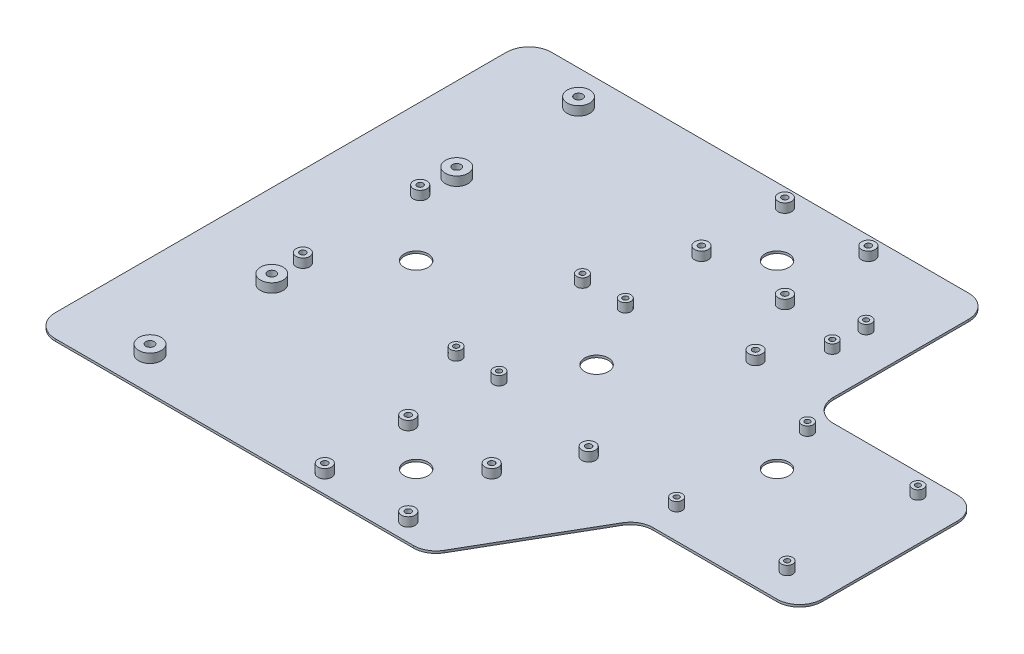
from build123d import *

# Parameters (mm, degrees)
SKETCH1_R              = 5
SKETCH1_R_2            = 1.85
BOSS_EXTRUDE1_DEPTH    = 5
SKETCH1_R_3            = 3
SKETCH1_R_4            = 1.35
BOSS_EXTRUDE1_2_DEPTH  = 5
BOSS_EXTRUDE1_3_DEPTH  = 5
BOSS_EXTRUDE1_4_DEPTH  = 5
BOSS_EXTRUDE1_5_DEPTH  = 5
SKETCH1_R_5            = 2.5
SKETCH1_R_6            = 1.15
BOSS_EXTRUDE1_6_DEPTH  = 5
BOSS_EXTRUDE1_7_DEPTH  = 5
BOSS_EXTRUDE1_8_DEPTH  = 5
BOSS_EXTRUDE1_9_DEPTH  = 5
BOSS_EXTRUDE1_10_DEPTH = 5
BOSS_EXTRUDE1_11_DEPTH = 5
BOSS_EXTRUDE1_12_DEPTH = 5
BOSS_EXTRUDE1_13_DEPTH = 5
BOSS_EXTRUDE1_14_DEPTH = 5
BOSS_EXTRUDE1_15_DEPTH = 5
BOSS_EXTRUDE1_16_DEPTH = 5
BOSS_EXTRUDE1_17_DEPTH = 5
BOSS_EXTRUDE1_18_DEPTH = 5
BOSS_EXTRUDE1_19_DEPTH = 5
BOSS_EXTRUDE1_20_DEPTH = 5
BOSS_EXTRUDE1_21_DEPTH = 5
BOSS_EXTRUDE1_22_DEPTH = 5
BOSS_EXTRUDE1_23_DEPTH = 5
BOSS_EXTRUDE1_24_DEPTH = 5
BOSS_EXTRUDE1_25_DEPTH = 5
BOSS_EXTRUDE1_26_DEPTH = 5
SKETCH1_4_R            = 5
SKETCH1_4_R_2          = 3
SKETCH1_4_R_3          = 2.5
SKETCH1_4_R_4          = 5.25
BOSS_EXTRUDE2_DEPTH    = 1


with BuildPart() as part:
    # Sketch1 → Boss-Extrude1 (new body)
    with BuildSketch(Plane(origin=(0, 0, 0), x_dir=(1, 0, 0), z_dir=(0, 1, 0))):
        with Locations((-103, -95)):
            Circle(SKETCH1_R)
        with Locations((-103, -95)):
            Circle(SKETCH1_R_2, mode=Mode.SUBTRACT)
    extrude(amount=BOSS_EXTRUDE1_DEPTH)



with BuildPart() as body_2:
    # Sketch1 → Boss-Extrude1 2 (new body)
    with BuildSketch(Plane(origin=(0, 0, 0), x_dir=(1, 0, 0), z_dir=(0, 1, 0))):
        with Locations((-18.5, -102)):
            Circle(SKETCH1_R_3)
        with Locations((-18.5, -102)):
            Circle(SKETCH1_R_4, mode=Mode.SUBTRACT)
    extrude(amount=BOSS_EXTRUDE1_2_DEPTH)


with BuildPart() as body_3:
    # Sketch1 → Boss-Extrude1 3 (new body)
    with BuildSketch(Plane(origin=(0, 0, 0), x_dir=(1, 0, 0), z_dir=(0, 1, 0))):
        with Locations((18.5, -102)):
            Circle(SKETCH1_R_3)
        with Locations((18.5, -102)):
            Circle(SKETCH1_R_4, mode=Mode.SUBTRACT)
    extrude(amount=BOSS_EXTRUDE1_3_DEPTH)


with BuildPart() as body_4:
    # Sketch1 → Boss-Extrude1 4 (new body)
    with BuildSketch(Plane(origin=(0, 0, 0), x_dir=(1, 0, 0), z_dir=(0, 1, 0))):
        with Locations((18.5, -65)):
            Circle(SKETCH1_R_3)
        with Locations((18.5, -65)):
            Circle(SKETCH1_R_4, mode=Mode.SUBTRACT)
    extrude(amount=BOSS_EXTRUDE1_4_DEPTH)


with BuildPart() as body_5:
    # Sketch1 → Boss-Extrude1 5 (new body)
    with BuildSketch(Plane(origin=(0, 0, 0), x_dir=(1, 0, 0), z_dir=(0, 1, 0))):
        with Locations((-18.5, -65)):
            Circle(SKETCH1_R_3)
        with Locations((-18.5, -65)):
            Circle(SKETCH1_R_4, mode=Mode.SUBTRACT)
    extrude(amount=BOSS_EXTRUDE1_5_DEPTH)


with BuildPart() as body_6:
    # Sketch1 → Boss-Extrude1 6 (new body)
    with BuildSketch(Plane(origin=(0, 0, 0), x_dir=(1, 0, 0), z_dir=(0, 1, 0))):
        with Locations((72.5, -37)):
            Circle(SKETCH1_R_5)
        with Locations((72.5, -37)):
            Circle(SKETCH1_R_6, mode=Mode.SUBTRACT)
    extrude(amount=BOSS_EXTRUDE1_6_DEPTH)


with BuildPart() as body_7:
    # Sketch1 → Boss-Extrude1 7 (new body)
    with BuildSketch(Plane(origin=(0, 0, 0), x_dir=(1, 0, 0), z_dir=(0, 1, 0))):
        with Locations((121.5, -37)):
            Circle(SKETCH1_R_5)
        with Locations((121.5, -37)):
            Circle(SKETCH1_R_6, mode=Mode.SUBTRACT)
    extrude(amount=BOSS_EXTRUDE1_7_DEPTH)


with BuildPart() as body_8:
    # Sketch1 → Boss-Extrude1 8 (new body)
    with BuildSketch(Plane(origin=(0, 0, 0), x_dir=(1, 0, 0), z_dir=(0, 1, 0))):
        with Locations((121.5, 21)):
            Circle(SKETCH1_R_5)
        with Locations((121.5, 21)):
            Circle(SKETCH1_R_6, mode=Mode.SUBTRACT)
    extrude(amount=BOSS_EXTRUDE1_8_DEPTH)


with BuildPart() as body_9:
    # Sketch1 → Boss-Extrude1 9 (new body)
    with BuildSketch(Plane(origin=(0, 0, 0), x_dir=(1, 0, 0), z_dir=(0, 1, 0))):
        with Locations((72.5, 21)):
            Circle(SKETCH1_R_5)
        with Locations((72.5, 21)):
            Circle(SKETCH1_R_6, mode=Mode.SUBTRACT)
    extrude(amount=BOSS_EXTRUDE1_9_DEPTH)


with BuildPart() as body_10:
    # Sketch1 → Boss-Extrude1 10 (new body)
    with BuildSketch(Plane(origin=(0, 0, 0), x_dir=(1, 0, 0), z_dir=(0, 1, 0))):
        with Locations((46.5, 58)):
            Circle(SKETCH1_R_5)
        with Locations((46.5, 58)):
            Circle(SKETCH1_R_6, mode=Mode.SUBTRACT)
    extrude(amount=BOSS_EXTRUDE1_10_DEPTH)


with BuildPart() as body_11:
    # Sketch1 → Boss-Extrude1 11 (new body)
    with BuildSketch(Plane(origin=(0, 0, 0), x_dir=(1, 0, 0), z_dir=(0, 1, 0))):
        with Locations((46.5, 73)):
            Circle(SKETCH1_R_5)
        with Locations((46.5, 73)):
            Circle(SKETCH1_R_6, mode=Mode.SUBTRACT)
    extrude(amount=BOSS_EXTRUDE1_11_DEPTH)


with BuildPart() as body_12:
    # Sketch1 → Boss-Extrude1 12 (new body)
    with BuildSketch(Plane(origin=(0, 0, 0), x_dir=(1, 0, 0), z_dir=(0, 1, 0))):
        with Locations((-18.5, 102)):
            Circle(SKETCH1_R_3)
        with Locations((-18.5, 102)):
            Circle(SKETCH1_R_4, mode=Mode.SUBTRACT)
    extrude(amount=BOSS_EXTRUDE1_12_DEPTH)


with BuildPart() as body_13:
    # Sketch1 → Boss-Extrude1 13 (new body)
    with BuildSketch(Plane(origin=(0, 0, 0), x_dir=(1, 0, 0), z_dir=(0, 1, 0))):
        with Locations((18.5, 102)):
            Circle(SKETCH1_R_3)
        with Locations((18.5, 102)):
            Circle(SKETCH1_R_4, mode=Mode.SUBTRACT)
    extrude(amount=BOSS_EXTRUDE1_13_DEPTH)


with BuildPart() as body_14:
    # Sketch1 → Boss-Extrude1 14 (new body)
    with BuildSketch(Plane(origin=(0, 0, 0), x_dir=(1, 0, 0), z_dir=(0, 1, 0))):
        with Locations((18.5, 65)):
            Circle(SKETCH1_R_3)
        with Locations((18.5, 65)):
            Circle(SKETCH1_R_4, mode=Mode.SUBTRACT)
    extrude(amount=BOSS_EXTRUDE1_14_DEPTH)


with BuildPart() as body_15:
    # Sketch1 → Boss-Extrude1 15 (new body)
    with BuildSketch(Plane(origin=(0, 0, 0), x_dir=(1, 0, 0), z_dir=(0, 1, 0))):
        with Locations((-18.5, 65)):
            Circle(SKETCH1_R_3)
        with Locations((-18.5, 65)):
            Circle(SKETCH1_R_4, mode=Mode.SUBTRACT)
    extrude(amount=BOSS_EXTRUDE1_15_DEPTH)


with BuildPart() as body_16:
    # Sketch1 → Boss-Extrude1 16 (new body)
    with BuildSketch(Plane(origin=(0, 0, 0), x_dir=(1, 0, 0), z_dir=(0, 1, 0))):
        with Locations((-103, 95)):
            Circle(SKETCH1_R)
        with Locations((-103, 95)):
            Circle(SKETCH1_R_2, mode=Mode.SUBTRACT)
    extrude(amount=BOSS_EXTRUDE1_16_DEPTH)


with BuildPart() as body_17:
    # Sketch1 → Boss-Extrude1 17 (new body)
    with BuildSketch(Plane(origin=(0, 0, 0), x_dir=(1, 0, 0), z_dir=(0, 1, 0))):
        with Locations((-103, 41)):
            Circle(SKETCH1_R)
        with Locations((-103, 41)):
            Circle(SKETCH1_R_2, mode=Mode.SUBTRACT)
    extrude(amount=BOSS_EXTRUDE1_17_DEPTH)


with BuildPart() as body_18:
    # Sketch1 → Boss-Extrude1 18 (new body)
    with BuildSketch(Plane(origin=(0, 0, 0), x_dir=(1, 0, 0), z_dir=(0, 1, 0))):
        with Locations((-104.2, 26)):
            Circle(SKETCH1_R_3)
        with Locations((-104.2, 26)):
            Circle(SKETCH1_R_4, mode=Mode.SUBTRACT)
    extrude(amount=BOSS_EXTRUDE1_18_DEPTH)


with BuildPart() as body_19:
    # Sketch1 → Boss-Extrude1 19 (new body)
    with BuildSketch(Plane(origin=(0, 0, 0), x_dir=(1, 0, 0), z_dir=(0, 1, 0))):
        with Locations((-104.2, -26)):
            Circle(SKETCH1_R_3)
        with Locations((-104.2, -26)):
            Circle(SKETCH1_R_4, mode=Mode.SUBTRACT)
    extrude(amount=BOSS_EXTRUDE1_19_DEPTH)


with BuildPart() as body_20:
    # Sketch1 → Boss-Extrude1 20 (new body)
    with BuildSketch(Plane(origin=(0, 0, 0), x_dir=(1, 0, 0), z_dir=(0, 1, 0))):
        with Locations((-103, -41)):
            Circle(SKETCH1_R)
        with Locations((-103, -41)):
            Circle(SKETCH1_R_2, mode=Mode.SUBTRACT)
    extrude(amount=BOSS_EXTRUDE1_20_DEPTH)


with BuildPart() as body_21:
    # Sketch1 → Boss-Extrude1 21 (new body)
    with BuildSketch(Plane(origin=(0, 0, 0), x_dir=(1, 0, 0), z_dir=(0, 1, 0))):
        with Locations((-15.25, -28)):
            Circle(SKETCH1_R_5)
        with Locations((-15.25, -28)):
            Circle(SKETCH1_R_6, mode=Mode.SUBTRACT)
    extrude(amount=BOSS_EXTRUDE1_21_DEPTH)


with BuildPart() as body_22:
    # Sketch1 → Boss-Extrude1 22 (new body)
    with BuildSketch(Plane(origin=(0, 0, 0), x_dir=(1, 0, 0), z_dir=(0, 1, 0))):
        with Locations((-34.25, -28)):
            Circle(SKETCH1_R_5)
        with Locations((-34.25, -28)):
            Circle(SKETCH1_R_6, mode=Mode.SUBTRACT)
    extrude(amount=BOSS_EXTRUDE1_22_DEPTH)


with BuildPart() as body_23:
    # Sketch1 → Boss-Extrude1 23 (new body)
    with BuildSketch(Plane(origin=(0, 0, 0), x_dir=(1, 0, 0), z_dir=(0, 1, 0))):
        with Locations((-34.25, 28)):
            Circle(SKETCH1_R_5)
        with Locations((-34.25, 28)):
            Circle(SKETCH1_R_6, mode=Mode.SUBTRACT)
    extrude(amount=BOSS_EXTRUDE1_23_DEPTH)


with BuildPart() as body_24:
    # Sketch1 → Boss-Extrude1 24 (new body)
    with BuildSketch(Plane(origin=(0, 0, 0), x_dir=(1, 0, 0), z_dir=(0, 1, 0))):
        with Locations((-15.25, 28)):
            Circle(SKETCH1_R_5)
        with Locations((-15.25, 28)):
            Circle(SKETCH1_R_6, mode=Mode.SUBTRACT)
    extrude(amount=BOSS_EXTRUDE1_24_DEPTH)


with BuildPart() as body_25:
    # Sketch1 → Boss-Extrude1 25 (new body)
    with BuildSketch(Plane(origin=(0, 0, 0), x_dir=(1, 0, 0), z_dir=(0, 1, 0))):
        with Locations((33.5, -37)):
            Circle(SKETCH1_R_3)
        with Locations((33.5, -37)):
            Circle(SKETCH1_R_4, mode=Mode.SUBTRACT)
    extrude(amount=BOSS_EXTRUDE1_25_DEPTH)


with BuildPart() as body_26:
    # Sketch1 → Boss-Extrude1 26 (new body)
    with BuildSketch(Plane(origin=(0, 0, 0), x_dir=(1, 0, 0), z_dir=(0, 1, 0))):
        with Locations((33.5, 37)):
            Circle(SKETCH1_R_3)
        with Locations((33.5, 37)):
            Circle(SKETCH1_R_4, mode=Mode.SUBTRACT)
    extrude(amount=BOSS_EXTRUDE1_26_DEPTH)


with BuildPart() as part_1:
    add(part.part)

    add(body_2.part)  # Boss-Extrude2 merges body 2

    add(body_3.part)  # Boss-Extrude2 merges body 3

    add(body_4.part)  # Boss-Extrude2 merges body 4

    add(body_5.part)  # Boss-Extrude2 merges body 5

    add(body_6.part)  # Boss-Extrude2 merges body 6

    add(body_7.part)  # Boss-Extrude2 merges body 7

    add(body_8.part)  # Boss-Extrude2 merges body 8

    add(body_9.part)  # Boss-Extrude2 merges body 9

    add(body_10.part)  # Boss-Extrude2 merges body 10

    add(body_11.part)  # Boss-Extrude2 merges body 11

    add(body_12.part)  # Boss-Extrude2 merges body 12

    add(body_13.part)  # Boss-Extrude2 merges body 13

    add(body_14.part)  # Boss-Extrude2 merges body 14

    add(body_15.part)  # Boss-Extrude2 merges body 15

    add(body_16.part)  # Boss-Extrude2 merges body 16

    add(body_17.part)  # Boss-Extrude2 merges body 17

    add(body_18.part)  # Boss-Extrude2 merges body 18

    add(body_19.part)  # Boss-Extrude2 merges body 19

    add(body_20.part)  # Boss-Extrude2 merges body 20

    add(body_21.part)  # Boss-Extrude2 merges body 21

    add(body_22.part)  # Boss-Extrude2 merges body 22

    add(body_23.part)  # Boss-Extrude2 merges body 23

    add(body_24.part)  # Boss-Extrude2 merges body 24

    add(body_25.part)  # Boss-Extrude2 merges body 25

    add(body_26.part)  # Boss-Extrude2 merges body 26
    # Sketch1_4 → Boss-Extrude2 (add)
    with BuildSketch(Plane(origin=(0, 0, 0), x_dir=(1, 0, 0), z_dir=(0, 1, 0))):
        with BuildLine():
            ThreePointArc((-130, 110), (-137.071067812, 107.071067812), (-140, 100))
            Line((-140, 100), (-140, -100))
            ThreePointArc((-140, -100), (-137.071067812, -107.071067812), (-130, -110))
            Line((-130, -110), (28.811978465, -110))
            ThreePointArc((28.811978465, -110), (33.811978465, -108.660254038), (37.472232503, -105))
            Line((37.472232503, -105), (66.339745962, -55))
            ThreePointArc((66.339745962, -55), (70, -51.339745962), (75, -50))
            Line((75, -50), (130, -50))
            ThreePointArc((130, -50), (137.071067812, -47.071067812), (140, -40))
            Line((140, -40), (140, 20))
            ThreePointArc((140, 20), (137.071067812, 27.071067812), (130, 30))
            Line((130, 30), (75, 30))
            ThreePointArc((75, 30), (67.928932188, 32.928932188), (65, 40))
            Line((65, 40), (65, 100))
            ThreePointArc((65, 100), (62.071067812, 107.071067812), (55, 110))
            Line((55, 110), (-130, 110))
        make_face()
        with Locations((-103, -95)):
            Circle(SKETCH1_4_R, mode=Mode.SUBTRACT)
        with Locations((-18.5, -102)):
            Circle(SKETCH1_4_R_2, mode=Mode.SUBTRACT)
        with Locations((-18.5, -65)):
            Circle(SKETCH1_4_R_2, mode=Mode.SUBTRACT)
        with Locations((-103, -41)):
            Circle(SKETCH1_4_R, mode=Mode.SUBTRACT)
        with Locations((-104.2, -26)):
            Circle(SKETCH1_4_R_2, mode=Mode.SUBTRACT)
        with Locations((-34.25, -28)):
            Circle(SKETCH1_4_R_3, mode=Mode.SUBTRACT)
        with Locations((-15.25, -28)):
            Circle(SKETCH1_4_R_3, mode=Mode.SUBTRACT)
        with Locations((18.5, -102)):
            Circle(SKETCH1_4_R_2, mode=Mode.SUBTRACT)
        with Locations((0, -80)):
            Circle(SKETCH1_4_R_4, mode=Mode.SUBTRACT)
        with Locations((18.5, -65)):
            Circle(SKETCH1_4_R_2, mode=Mode.SUBTRACT)
        with Locations((33.5, -37)):
            Circle(SKETCH1_4_R_2, mode=Mode.SUBTRACT)
        with Locations((72.5, -37)):
            Circle(SKETCH1_4_R_3, mode=Mode.SUBTRACT)
        with Locations((121.5, -37)):
            Circle(SKETCH1_4_R_3, mode=Mode.SUBTRACT)
        with Locations((-80, 0)):
            Circle(SKETCH1_4_R_4, mode=Mode.SUBTRACT)
        with Locations((-104.2, 26)):
            Circle(SKETCH1_4_R_2, mode=Mode.SUBTRACT)
        with Locations((-103, 41)):
            Circle(SKETCH1_4_R, mode=Mode.SUBTRACT)
        with Locations((-34.25, 28)):
            Circle(SKETCH1_4_R_3, mode=Mode.SUBTRACT)
        with Locations((-15.25, 28)):
            Circle(SKETCH1_4_R_3, mode=Mode.SUBTRACT)
        with Locations((-103, 95)):
            Circle(SKETCH1_4_R, mode=Mode.SUBTRACT)
        with Locations((-18.5, 65)):
            Circle(SKETCH1_4_R_2, mode=Mode.SUBTRACT)
        with Locations((-18.5, 102)):
            Circle(SKETCH1_4_R_2, mode=Mode.SUBTRACT)
        Circle(SKETCH1_4_R_4, mode=Mode.SUBTRACT)
        with Locations((33.5, 37)):
            Circle(SKETCH1_4_R_2, mode=Mode.SUBTRACT)
        with Locations((80, 0)):
            Circle(SKETCH1_4_R_4, mode=Mode.SUBTRACT)
        with Locations((72.5, 21)):
            Circle(SKETCH1_4_R_3, mode=Mode.SUBTRACT)
        with Locations((121.5, 21)):
            Circle(SKETCH1_4_R_3, mode=Mode.SUBTRACT)
        with Locations((18.5, 65)):
            Circle(SKETCH1_4_R_2, mode=Mode.SUBTRACT)
        with Locations((0, 80)):
            Circle(SKETCH1_4_R_4, mode=Mode.SUBTRACT)
        with Locations((46.5, 58)):
            Circle(SKETCH1_4_R_3, mode=Mode.SUBTRACT)
        with Locations((46.5, 73)):
            Circle(SKETCH1_4_R_3, mode=Mode.SUBTRACT)
        with Locations((18.5, 102)):
            Circle(SKETCH1_4_R_2, mode=Mode.SUBTRACT)
    extrude(amount=BOSS_EXTRUDE2_DEPTH)


solid = part_1.part
